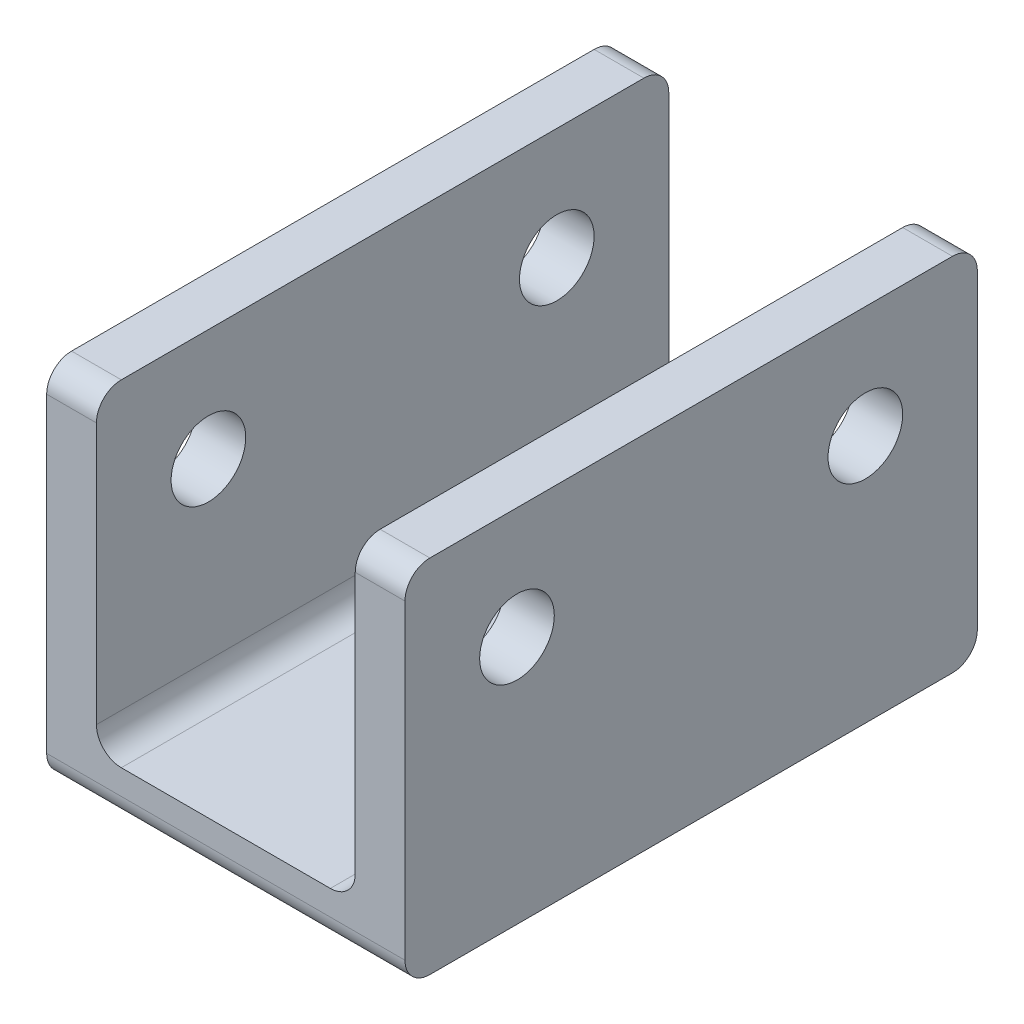
from build123d import *

# Parameters (mm, degrees)
BOSS_EXTRUDE1_DEPTH     = 11.5
SKETCH2_R               = 1.5
CUT_EXTRUDE1_DEPTH      = 1
CUT_EXTRUDE1_DEPTH_BACK = 15.4
FILLET1_R               = 1
FILLET2_R               = 1
FILLET3_R               = 1


with BuildPart() as part:
    # Sketch1 → Boss-Extrude1 (new body, symmetric)
    with BuildSketch(Plane.XY):
        Polygon((-5.2, 1), (5.2, 1), (5.2, 13.5), (7.2, 13.5), (7.2, -1), (-7.2, -1), (-7.2, 13.5), (-5.2, 13.5), align=None)
    extrude(amount=BOSS_EXTRUDE1_DEPTH, both=True)

    # Sketch2 → Cut-Extrude1 (cut, two sides)
    with BuildSketch(Plane(origin=(7.2, 0, 0), x_dir=(0, 0, -1), z_dir=(1, 0, 0))) as cut_extrude1_sk:
        with Locations((-7, 9)):
            Circle(SKETCH2_R)
        with Locations((7, 9)):
            Circle(SKETCH2_R)
    extrude(amount=CUT_EXTRUDE1_DEPTH, mode=Mode.SUBTRACT)
    extrude(cut_extrude1_sk.sketch, amount=-CUT_EXTRUDE1_DEPTH_BACK, mode=Mode.SUBTRACT)

    # Fillet1
    fillet1_edges = [part.edges().sort_by_distance(p)[0] for p in [
        (0, -1, -11.5),
        (0, -1, 11.5),
    ]]
    fillet(fillet1_edges, radius=FILLET1_R)

    # Fillet2
    fillet2_edges = [part.edges().sort_by_distance(p)[0] for p in [
        (-5.2, 1, 0),
        (5.2, 1, 0),
    ]]
    fillet(fillet2_edges, radius=FILLET2_R)

    # Fillet3
    fillet3_edges = [part.edges().sort_by_distance(p)[0] for p in [
        (-6.2, 13.5, -11.5),
        (6.2, 13.5, 11.5),
        (-6.2, 13.5, 11.5),
        (6.2, 13.5, -11.5),
    ]]
    fillet(fillet3_edges, radius=FILLET3_R)


solid = part.part
